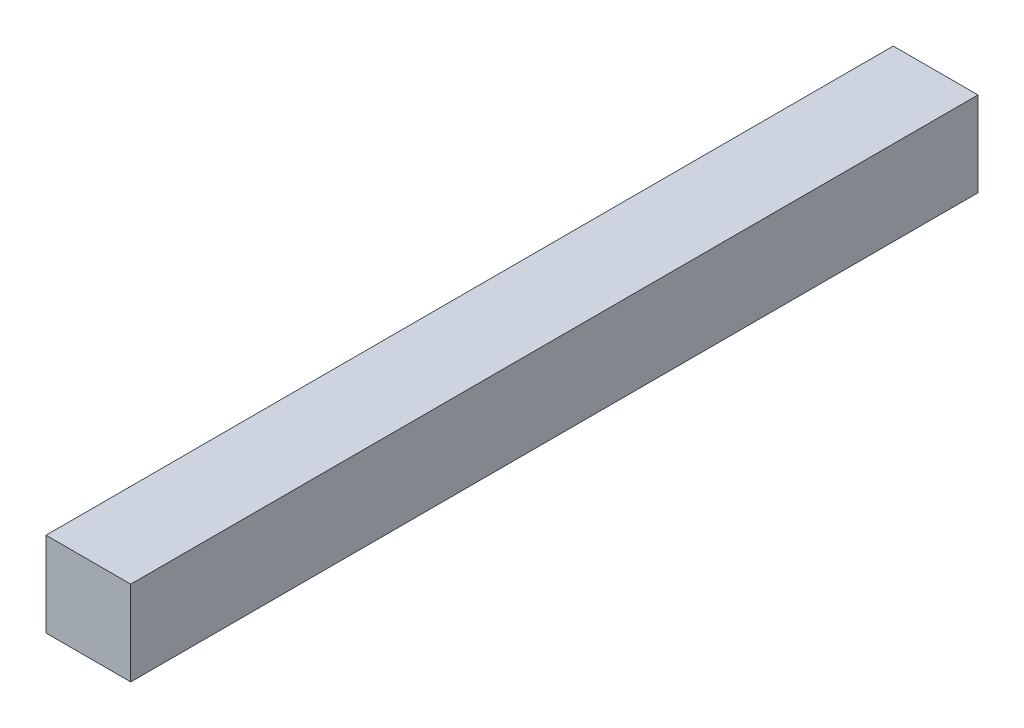
from build123d import *

# Parameters (mm, degrees)
SKETCH1_W           = 10
SKETCH1_H           = 10
BOSS_EXTRUDE1_DEPTH = 100


with BuildPart() as part:
    # Sketch1 → Boss-Extrude1 (new body)
    with BuildSketch(Plane.XY):
        with Locations((-42.30753192, 22.950870431)):
            Rectangle(SKETCH1_W, SKETCH1_H)
    extrude(amount=BOSS_EXTRUDE1_DEPTH)


solid = part.part
